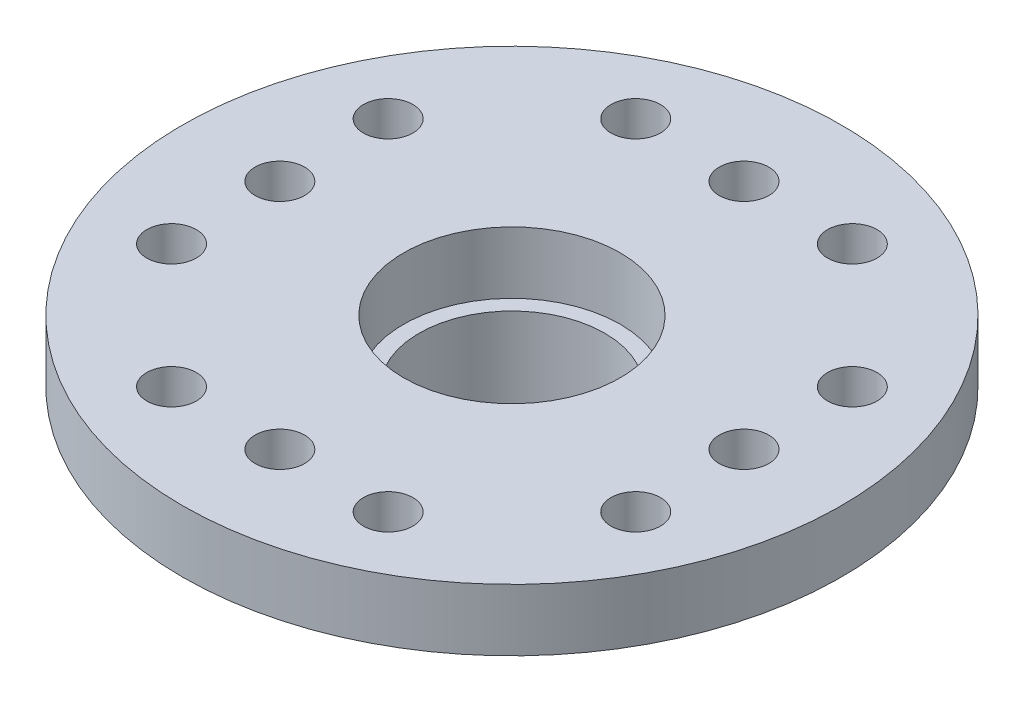
from build123d import *

# Parameters (mm, degrees)
SKETCH_1_R          = 10.65
SKETCH_1_R_2        = 3.5
EXTRUDE_1_DEPTH     = 2
SKETCH_2_R          = 4.3
SKETCH_2_R_2        = 3
EXTRUDE_2_DEPTH     = 3.8
FILLET_1_R          = 1
CUT_EXTRUDE_1_REACH = 7.8
SKETCH_3_R          = 0.8


with BuildPart() as part:
    # Эскиз1 → Бобышка-Вытянуть1 (new body)
    with BuildSketch(Plane(origin=(0, 0, 0), x_dir=(1, 0, 0), z_dir=(0, 1, 0))):
        Circle(SKETCH_1_R)
        Circle(SKETCH_1_R_2, mode=Mode.SUBTRACT)
    extrude(amount=EXTRUDE_1_DEPTH)

    # Эскиз2 → Бобышка-Вытянуть2 (add)
    with BuildSketch(Plane.XZ):
        Circle(SKETCH_2_R)
        Circle(SKETCH_2_R_2, mode=Mode.SUBTRACT)
    extrude(amount=EXTRUDE_2_DEPTH)

    # Скругление1
    fillet_1_edges = [part.edges().sort_by_distance(p)[0] for p in [
        (-4.3, 0, 0),
    ]]
    fillet(fillet_1_edges, radius=FILLET_1_R)

    # Эскиз3 → Вырез-Вытянуть1 (cut, up to next)
    with BuildSketch(Plane(origin=(0, 2, 0), x_dir=(1, 0, 0), z_dir=(0, 1, 0)), mode=Mode.PRIVATE) as cut_extrude_1_sk1:
        with Locations((-3.5, 7.5)):
            Circle(SKETCH_3_R)
    cut_extrude_1_tool1 = extrude(cut_extrude_1_sk1.sketch, amount=-CUT_EXTRUDE_1_REACH, mode=Mode.PRIVATE) & part.part
    add(cut_extrude_1_tool1.solids().sort_by_distance((-3.5, 2, -7.5))[0], mode=Mode.SUBTRACT)
    # Эскиз3 → Вырез-Вытянуть1 (cut, up to next)
    with BuildSketch(Plane(origin=(0, 2, 0), x_dir=(1, 0, 0), z_dir=(0, 1, 0)), mode=Mode.PRIVATE) as cut_extrude_1_sk2:
        with Locations((0, 7.5)):
            Circle(SKETCH_3_R)
    cut_extrude_1_tool2 = extrude(cut_extrude_1_sk2.sketch, amount=-CUT_EXTRUDE_1_REACH, mode=Mode.PRIVATE) & part.part
    add(cut_extrude_1_tool2.solids().sort_by_distance((0, 2, -7.5))[0], mode=Mode.SUBTRACT)
    # Эскиз3 → Вырез-Вытянуть1 (cut, up to next)
    with BuildSketch(Plane(origin=(0, 2, 0), x_dir=(1, 0, 0), z_dir=(0, 1, 0)), mode=Mode.PRIVATE) as cut_extrude_1_sk3:
        with Locations((3.5, 7.5)):
            Circle(SKETCH_3_R)
    cut_extrude_1_tool3 = extrude(cut_extrude_1_sk3.sketch, amount=-CUT_EXTRUDE_1_REACH, mode=Mode.PRIVATE) & part.part
    add(cut_extrude_1_tool3.solids().sort_by_distance((3.5, 2, -7.5))[0], mode=Mode.SUBTRACT)
    # Эскиз3 → Вырез-Вытянуть1 (cut, up to next)
    with BuildSketch(Plane(origin=(0, 2, 0), x_dir=(1, 0, 0), z_dir=(0, 1, 0)), mode=Mode.PRIVATE) as cut_extrude_1_sk4:
        with Locations((7.5, 3.5)):
            Circle(SKETCH_3_R)
    cut_extrude_1_tool4 = extrude(cut_extrude_1_sk4.sketch, amount=-CUT_EXTRUDE_1_REACH, mode=Mode.PRIVATE) & part.part
    add(cut_extrude_1_tool4.solids().sort_by_distance((7.5, 2, -3.5))[0], mode=Mode.SUBTRACT)
    # Эскиз3 → Вырез-Вытянуть1 (cut, up to next)
    with BuildSketch(Plane(origin=(0, 2, 0), x_dir=(1, 0, 0), z_dir=(0, 1, 0)), mode=Mode.PRIVATE) as cut_extrude_1_sk5:
        with Locations((7.5, 0)):
            Circle(SKETCH_3_R)
    cut_extrude_1_tool5 = extrude(cut_extrude_1_sk5.sketch, amount=-CUT_EXTRUDE_1_REACH, mode=Mode.PRIVATE) & part.part
    add(cut_extrude_1_tool5.solids().sort_by_distance((7.5, 2, 0))[0], mode=Mode.SUBTRACT)
    # Эскиз3 → Вырез-Вытянуть1 (cut, up to next)
    with BuildSketch(Plane(origin=(0, 2, 0), x_dir=(1, 0, 0), z_dir=(0, 1, 0)), mode=Mode.PRIVATE) as cut_extrude_1_sk6:
        with Locations((7.5, -3.5)):
            Circle(SKETCH_3_R)
    cut_extrude_1_tool6 = extrude(cut_extrude_1_sk6.sketch, amount=-CUT_EXTRUDE_1_REACH, mode=Mode.PRIVATE) & part.part
    add(cut_extrude_1_tool6.solids().sort_by_distance((7.5, 2, 3.5))[0], mode=Mode.SUBTRACT)
    # Эскиз3 → Вырез-Вытянуть1 (cut, up to next)
    with BuildSketch(Plane(origin=(0, 2, 0), x_dir=(1, 0, 0), z_dir=(0, 1, 0)), mode=Mode.PRIVATE) as cut_extrude_1_sk7:
        with Locations((3.5, -7.5)):
            Circle(SKETCH_3_R)
    cut_extrude_1_tool7 = extrude(cut_extrude_1_sk7.sketch, amount=-CUT_EXTRUDE_1_REACH, mode=Mode.PRIVATE) & part.part
    add(cut_extrude_1_tool7.solids().sort_by_distance((3.5, 2, 7.5))[0], mode=Mode.SUBTRACT)
    # Эскиз3 → Вырез-Вытянуть1 (cut, up to next)
    with BuildSketch(Plane(origin=(0, 2, 0), x_dir=(1, 0, 0), z_dir=(0, 1, 0)), mode=Mode.PRIVATE) as cut_extrude_1_sk8:
        with Locations((0, -7.5)):
            Circle(SKETCH_3_R)
    cut_extrude_1_tool8 = extrude(cut_extrude_1_sk8.sketch, amount=-CUT_EXTRUDE_1_REACH, mode=Mode.PRIVATE) & part.part
    add(cut_extrude_1_tool8.solids().sort_by_distance((0, 2, 7.5))[0], mode=Mode.SUBTRACT)
    # Эскиз3 → Вырез-Вытянуть1 (cut, up to next)
    with BuildSketch(Plane(origin=(0, 2, 0), x_dir=(1, 0, 0), z_dir=(0, 1, 0)), mode=Mode.PRIVATE) as cut_extrude_1_sk9:
        with Locations((-3.5, -7.5)):
            Circle(SKETCH_3_R)
    cut_extrude_1_tool9 = extrude(cut_extrude_1_sk9.sketch, amount=-CUT_EXTRUDE_1_REACH, mode=Mode.PRIVATE) & part.part
    add(cut_extrude_1_tool9.solids().sort_by_distance((-3.5, 2, 7.5))[0], mode=Mode.SUBTRACT)
    # Эскиз3 → Вырез-Вытянуть1 (cut, up to next)
    with BuildSketch(Plane(origin=(0, 2, 0), x_dir=(1, 0, 0), z_dir=(0, 1, 0)), mode=Mode.PRIVATE) as cut_extrude_1_sk10:
        with Locations((-7.5, -3.5)):
            Circle(SKETCH_3_R)
    cut_extrude_1_tool10 = extrude(cut_extrude_1_sk10.sketch, amount=-CUT_EXTRUDE_1_REACH, mode=Mode.PRIVATE) & part.part
    add(cut_extrude_1_tool10.solids().sort_by_distance((-7.5, 2, 3.5))[0], mode=Mode.SUBTRACT)
    # Эскиз3 → Вырез-Вытянуть1 (cut, up to next)
    with BuildSketch(Plane(origin=(0, 2, 0), x_dir=(1, 0, 0), z_dir=(0, 1, 0)), mode=Mode.PRIVATE) as cut_extrude_1_sk11:
        with Locations((-7.5, 0)):
            Circle(SKETCH_3_R)
    cut_extrude_1_tool11 = extrude(cut_extrude_1_sk11.sketch, amount=-CUT_EXTRUDE_1_REACH, mode=Mode.PRIVATE) & part.part
    add(cut_extrude_1_tool11.solids().sort_by_distance((-7.5, 2, 0))[0], mode=Mode.SUBTRACT)
    # Эскиз3 → Вырез-Вытянуть1 (cut, up to next)
    with BuildSketch(Plane(origin=(0, 2, 0), x_dir=(1, 0, 0), z_dir=(0, 1, 0)), mode=Mode.PRIVATE) as cut_extrude_1_sk12:
        with Locations((-7.5, 3.5)):
            Circle(SKETCH_3_R)
    cut_extrude_1_tool12 = extrude(cut_extrude_1_sk12.sketch, amount=-CUT_EXTRUDE_1_REACH, mode=Mode.PRIVATE) & part.part
    add(cut_extrude_1_tool12.solids().sort_by_distance((-7.5, 2, -3.5))[0], mode=Mode.SUBTRACT)


solid = part.part
